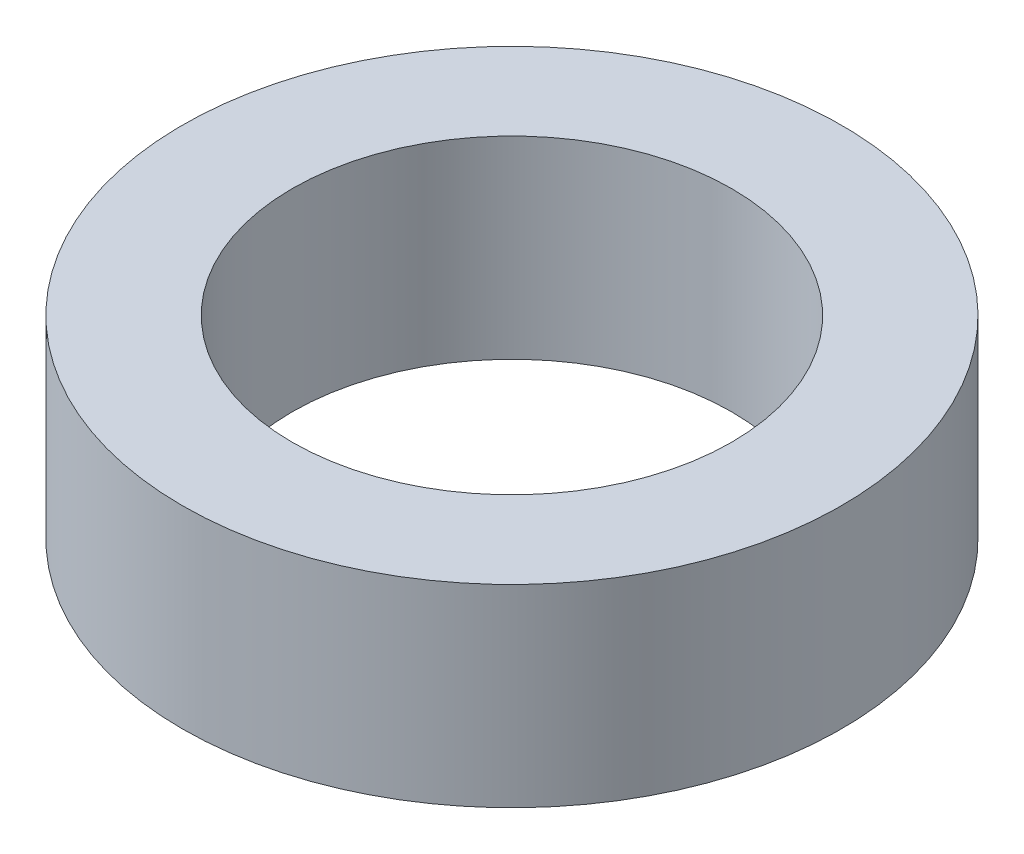
from build123d import *

# Parameters (mm, degrees)
SKETCH1_R           = 9.525
SKETCH1_R_2         = 6.35
BOSS_EXTRUDE1_DEPTH = 5.588


with BuildPart() as part:
    # Sketch1 → Boss-Extrude1 (new body)
    with BuildSketch(Plane(origin=(0, 0, 0), x_dir=(1, 0, 0), z_dir=(0, 1, 0))):
        Circle(SKETCH1_R)
        Circle(SKETCH1_R_2, mode=Mode.SUBTRACT)
    extrude(amount=BOSS_EXTRUDE1_DEPTH)


solid = part.part
